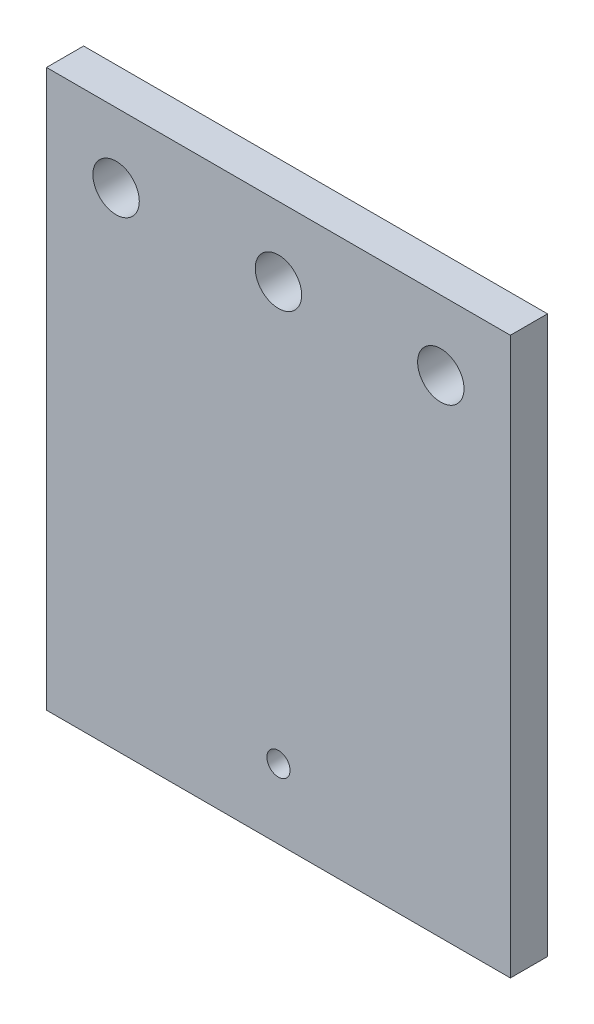
from build123d import *

# Parameters (mm, degrees)
SKETCH1_W           = 127
SKETCH1_H           = 152.4
SKETCH1_R           = 3.175
SKETCH1_R_2         = 6.35
BOSS_EXTRUDE1_DEPTH = 10.16


with BuildPart() as part:
    # Sketch1 → Boss-Extrude1 (new body)
    with BuildSketch(Plane.XY):
        with Locations((63.5, 76.2)):
            Rectangle(SKETCH1_W, SKETCH1_H)
        with Locations((63.5, 19.05)):
            Circle(SKETCH1_R, mode=Mode.SUBTRACT)
        with Locations((19.05, 133.35)):
            Circle(SKETCH1_R_2, mode=Mode.SUBTRACT)
        with Locations((63.5, 133.35)):
            Circle(SKETCH1_R_2, mode=Mode.SUBTRACT)
        with Locations((107.95, 133.35)):
            Circle(SKETCH1_R_2, mode=Mode.SUBTRACT)
    extrude(amount=BOSS_EXTRUDE1_DEPTH)


solid = part.part
